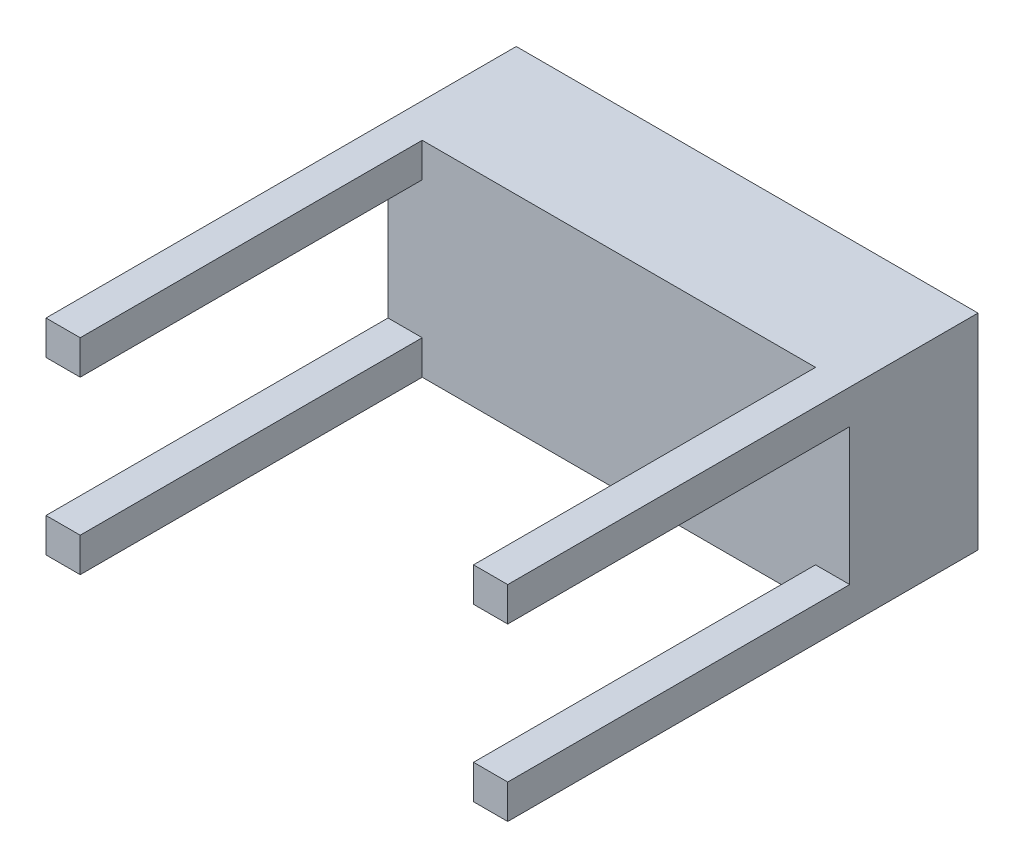
from build123d import *

# Parameters (mm, degrees)
ESBO_O1_W                = 540
ESBO_O1_H                = 240
RESSALTO_EXTRUS_O1_DEPTH = 150
ESBO_O2_W                = 40
ESBO_O2_H                = 40
RESSALTO_EXTRUS_O2_DEPTH = 400


with BuildPart() as part:
    # Esboço1 → Ressalto-extrusão1 (new body)
    with BuildSketch(Plane.XY):
        with Locations((-270, 120)):
            Rectangle(ESBO_O1_W, ESBO_O1_H)
    extrude(amount=RESSALTO_EXTRUS_O1_DEPTH)

    # Esboço2 → Ressalto-extrusão2 (add)
    with BuildSketch(Plane.XY.offset(150)):
        with Locations((-520, 220)):
            Rectangle(ESBO_O2_W, ESBO_O2_H)
        with Locations((-520, 20)):
            Rectangle(ESBO_O2_W, ESBO_O2_H)
        with Locations((-20, 20)):
            Rectangle(ESBO_O2_W, ESBO_O2_H)
        with Locations((-20, 220)):
            Rectangle(ESBO_O2_W, ESBO_O2_H)
    extrude(amount=RESSALTO_EXTRUS_O2_DEPTH)


solid = part.part
